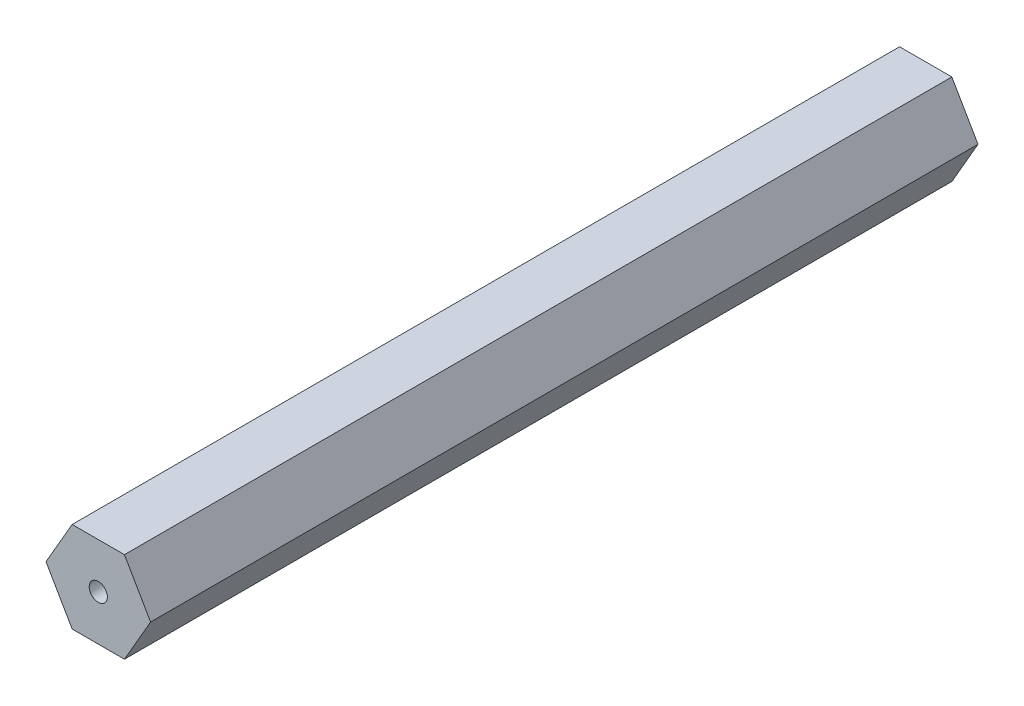
from build123d import *

# Parameters (mm, degrees)
SKETCH1_R           = 1.27
BOSS_EXTRUDE1_DEPTH = 116.0272


with BuildPart() as part:
    # Sketch1 → Boss-Extrude1 (new body)
    with BuildSketch(Plane.XY):
        Polygon((7.332348419, 0), (3.666174209, 6.35), (-3.666174209, 6.35), (-7.332348419, 0), (-3.666174209, -6.35), (3.666174209, -6.35), align=None)
        Circle(SKETCH1_R, mode=Mode.SUBTRACT)
    extrude(amount=BOSS_EXTRUDE1_DEPTH)


solid = part.part
